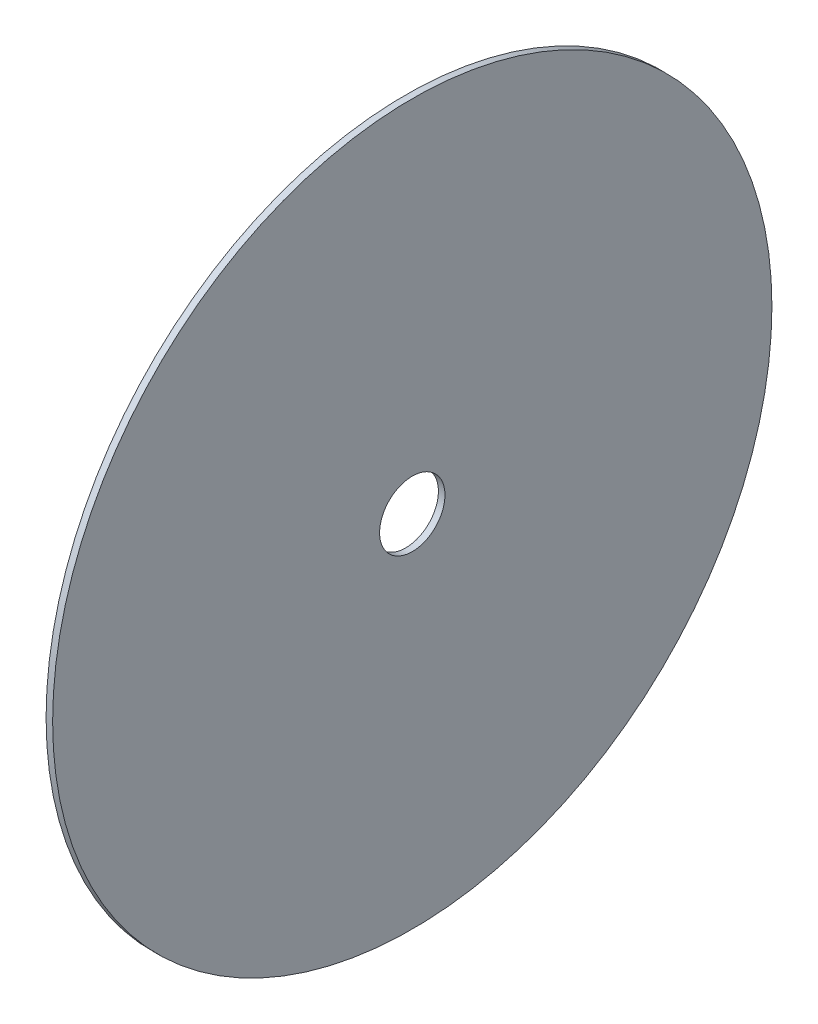
from build123d import *

# Parameters (mm, degrees)
SKETCH_1_R      = 110
SKETCH_1_R_2    = 10
EXTRUDE_1_DEPTH = 2


with BuildPart() as part:
    # Эскиз1 → Бобышка-Вытянуть1 (new body)
    with BuildSketch(Plane(origin=(0, 0, 0), x_dir=(0, 0, -1), z_dir=(1, 0, 0))):
        Circle(SKETCH_1_R)
        Circle(SKETCH_1_R_2, mode=Mode.SUBTRACT)
    extrude(amount=EXTRUDE_1_DEPTH)


solid = part.part
